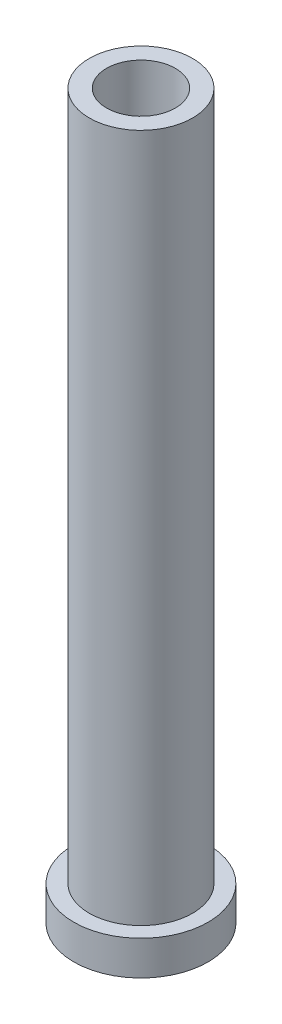
from build123d import *

# Parameters (mm, degrees)
SKETCH1_R           = 3.9
BOSS_EXTRUDE1_DEPTH = 2
SKETCH2_R           = 3
BOSS_EXTRUDE2_DEPTH = 40
SKETCH3_R           = 2
CUT_EXTRUDE1_DEPTH  = 5


with BuildPart() as part:
    # Sketch1 → Boss-Extrude1 (new body)
    with BuildSketch(Plane(origin=(0, 0, 0), x_dir=(1, 0, 0), z_dir=(0, 1, 0))):
        Circle(SKETCH1_R)
    extrude(amount=-BOSS_EXTRUDE1_DEPTH)

    # Sketch2 → Boss-Extrude2 (add)
    with BuildSketch(Plane(origin=(0, 0, 0), x_dir=(1, 0, 0), z_dir=(0, 1, 0))):
        Circle(SKETCH2_R)
    extrude(amount=BOSS_EXTRUDE2_DEPTH)

    # Sketch3 → Cut-Extrude1 (cut)
    with BuildSketch(Plane(origin=(0, 40, 0), x_dir=(1, 0, 0), z_dir=(0, 1, 0))):
        Circle(SKETCH3_R)
    extrude(amount=-CUT_EXTRUDE1_DEPTH, mode=Mode.SUBTRACT)


solid = part.part
